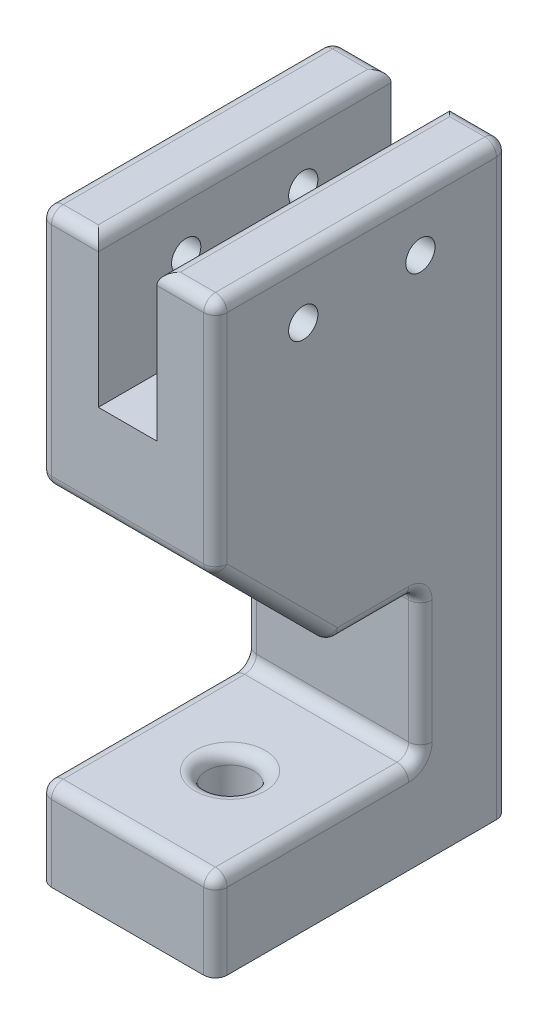
from build123d import *

# Parameters (mm, degrees)
BOSS_EXTRUDE1_DEPTH = 30
SKETCH3_R           = 4
CUT_EXTRUDE1_DEPTH  = 30
SKETCH4_W           = 10
SKETCH4_H           = 50
CUT_EXTRUDE2_DEPTH  = 51
SKETCH5_R           = 2.5
CUT_EXTRUDE3_DEPTH  = 30
FILLET1_R           = 2
CUT_EXTRUDE4_DEPTH  = 31
FILLET2_R           = 2


with BuildPart() as part:
    # Sketch2 → Boss-Extrude1 (new body)
    with BuildSketch(Plane(origin=(0, 0, 0), x_dir=(0, 0, -1), z_dir=(1, 0, 0))):
        Polygon((0, 40), (35, 40), (35, 15), (0, 15), (0, 0), (50, 0), (50, 100), (0, 100), align=None)
    extrude(amount=BOSS_EXTRUDE1_DEPTH)

    # Sketch3 → Cut-Extrude1 (cut)
    with BuildSketch(Plane(origin=(0, 15, 0), x_dir=(1, 0, 0), z_dir=(0, 1, 0))):
        with Locations((15, 17.5)):
            Circle(SKETCH3_R)
    extrude(amount=-CUT_EXTRUDE1_DEPTH, mode=Mode.SUBTRACT)

    # Sketch4 → Cut-Extrude2 (cut, through all)
    with BuildSketch(Plane.XY):
        with Locations((15, 100)):
            Rectangle(SKETCH4_W, SKETCH4_H)
    extrude(amount=-CUT_EXTRUDE2_DEPTH, mode=Mode.SUBTRACT)

    # Sketch5 → Cut-Extrude3 (cut)
    with BuildSketch(Plane.ZY):
        with Locations((-35, 90)):
            Circle(SKETCH5_R)
        with Locations((-15, 90)):
            Circle(SKETCH5_R)
    extrude(amount=-CUT_EXTRUDE3_DEPTH, mode=Mode.SUBTRACT)

    # Fillet1
    fillet1_edges = [part.edges().sort_by_distance(p)[0] for p in [
        (11, 15, -17.5),
    ]]
    fillet(fillet1_edges, radius=FILLET1_R)

    # Sketch6 → Cut-Extrude4 (cut, through all)
    with BuildSketch(Plane.ZY):
        Polygon((-20, 40), (0, 60), (0, 40), align=None)
    extrude(amount=-CUT_EXTRUDE4_DEPTH, mode=Mode.SUBTRACT)

    # Fillet2
    fillet2_edges = [part.edges().sort_by_distance(p)[0] for p in [
        (30, 50, -50),
        (0, 100, -25),
        (15, 40, -35),
        (15, 15, -35),
        (15, 15, 0),
        (25, 100, -50),
        (25, 100, 0),
        (30, 7.5, 0),
        (30, 15, -17.5),
        (30, 27.5, -35),
        (5, 100, 0),
        (5, 100, -50),
        (10, 100, -25),
        (20, 100, -25),
        (30, 100, -25),
        (0, 80, 0),
        (0, 40, -27.5),
        (30, 80, 0),
        (30, 40, -27.5),
        (30, 50, -10),
        (15, 40, -20),
        (15, 60, 0),
        (0, 50, -10),
        (0, 27.5, -35),
        (0, 15, -17.5),
        (0, 7.5, 0),
        (0, 50, -50),
    ]]
    fillet(fillet2_edges, radius=FILLET2_R)


solid = part.part
